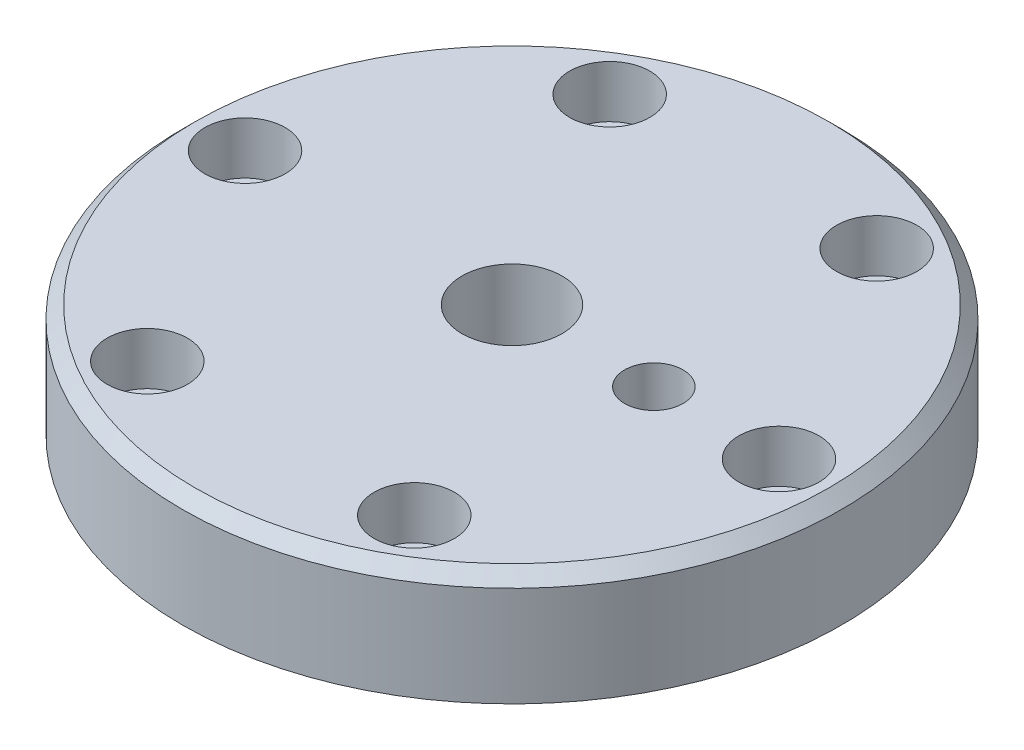
from build123d import *

# Parameters (mm, degrees)
SKETCH1_R                               = 79
SKETCH1_R_2                             = 12
BOSS_EXTRUDE1_DEPTH                     = 27
CBORE_FOR_M5_HEX_HEAD_BOLT1_D           = 12.5
CBORE_FOR_M5_HEX_HEAD_BOLT1_CBORE_D     = 19.25
CBORE_FOR_M5_HEX_HEAD_BOLT1_CBORE_DEPTH = 12.5
F_1_0MM_DOWEL_HOLE1_D                   = 14
F_1_0MM_DOWEL_HOLE1_DEPTH               = 17
F_1_0MM_DOWEL_HOLE1_TIP                 = 4.206024333
SKETCH8_R                               = 33
SKETCH8_R_2                             = 22
CUT_EXTRUDE1_DEPTH                      = 6
CHAMFER1_SIZE                           = 3


with BuildPart() as part:
    # Sketch1 → Boss-Extrude1 (new body)
    with BuildSketch(Plane(origin=(0, 0, 0), x_dir=(1, 0, 0), z_dir=(0, 1, 0))):
        Circle(SKETCH1_R)
        Circle(SKETCH1_R_2, mode=Mode.SUBTRACT)
    extrude(amount=BOSS_EXTRUDE1_DEPTH)

    # CBORE for M5 Hex Head Bolt1 (through all)
    with Locations(Plane(origin=(0, 27, 0), x_dir=(1, 0, 0), z_dir=(0, 1, 0))):
        with Locations((32, 55.425625842), (64, 0), (32, -55.425625842), (-32, -55.425625842), (-64, 0), (-32, 55.425625842), (0, 0)):
            CounterBoreHole(CBORE_FOR_M5_HEX_HEAD_BOLT1_D / 2, CBORE_FOR_M5_HEX_HEAD_BOLT1_CBORE_D / 2, CBORE_FOR_M5_HEX_HEAD_BOLT1_CBORE_DEPTH)

    # Ø1.0mm Dowel Hole1
    with Locations(Plane(origin=(0, 27, 0), x_dir=(1, 0, 0), z_dir=(0, 1, 0))):
        with Locations((34, 0)):
            Hole(F_1_0MM_DOWEL_HOLE1_D / 2, depth=F_1_0MM_DOWEL_HOLE1_DEPTH)
            with Locations((0, 0, -(F_1_0MM_DOWEL_HOLE1_DEPTH + F_1_0MM_DOWEL_HOLE1_TIP / 2))):  # 118° drill point
                Cone(0, F_1_0MM_DOWEL_HOLE1_D / 2, F_1_0MM_DOWEL_HOLE1_TIP, mode=Mode.SUBTRACT)

    # Sketch8 → Cut-Extrude1 (cut)
    with BuildSketch(Plane(origin=(0, 0, 0), x_dir=(1, 0, 0), z_dir=(0, 1, 0))):
        Circle(SKETCH8_R)
        Circle(SKETCH8_R_2, mode=Mode.SUBTRACT)
    extrude(amount=CUT_EXTRUDE1_DEPTH, mode=Mode.SUBTRACT)

    # Chamfer1
    chamfer1_edges = [part.edges().sort_by_distance(p)[0] for p in [
        (-79, 27, 0),
    ]]
    chamfer(chamfer1_edges, length=CHAMFER1_SIZE)


solid = part.part
